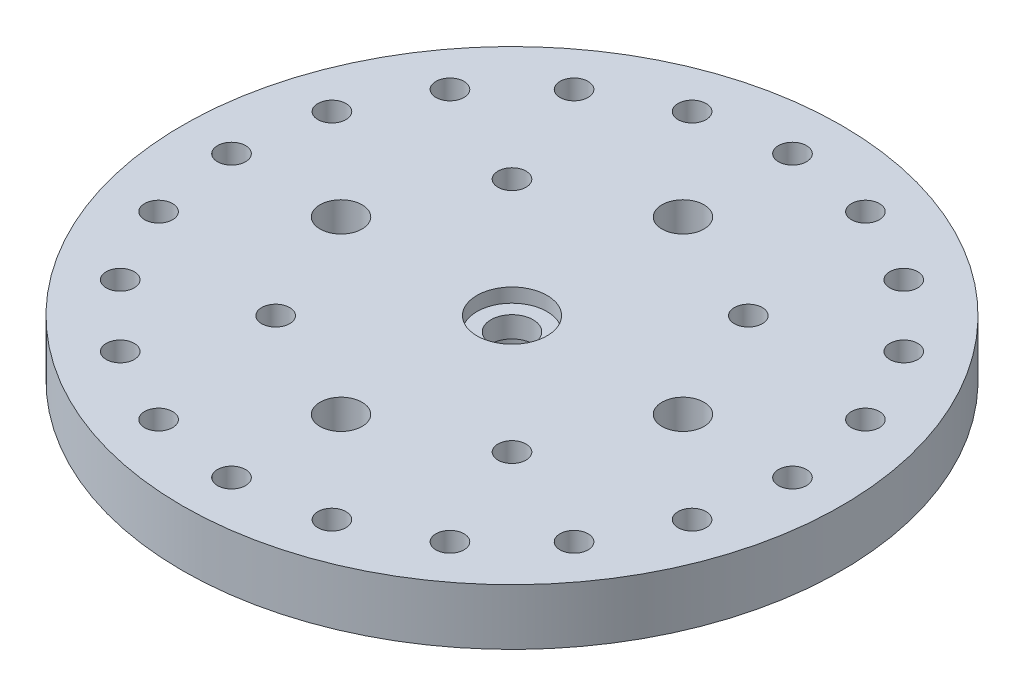
from build123d import *

# Parameters (mm, degrees)
SKETCH1_R           = 23.5
SKETCH1_R_2         = 1.5
SKETCH1_R_3         = 1
BOSS_EXTRUDE1_DEPTH = 4
SKETCH2_R           = 2.7
CUT_EXTRUDE1_DEPTH  = 1.5
SKETCH3_R           = 2.5
CUT_EXTRUDE2_DEPTH  = 1
SKETCH4_R           = 3.7
SKETCH4_R_2         = 2.7
EXTRUDE_THIN1_DEPTH = 1


with BuildPart() as part:
    # Sketch1 → Boss-Extrude1 (new body)
    with BuildSketch(Plane(origin=(0, 0, 0), x_dir=(1, 0, 0), z_dir=(0, 1, 0))):
        Circle(SKETCH1_R)
        Circle(SKETCH1_R_2, mode=Mode.SUBTRACT)
        with Locations((0, 20)):
            Circle(SKETCH1_R_3, mode=Mode.SUBTRACT)
        with Locations((6.180339887, 19.021130326)):
            Circle(SKETCH1_R_3, mode=Mode.SUBTRACT)
        with Locations((11.755705046, 16.180339887)):
            Circle(SKETCH1_R_3, mode=Mode.SUBTRACT)
        with Locations((16.180339887, 11.755705046)):
            Circle(SKETCH1_R_3, mode=Mode.SUBTRACT)
        with Locations((19.021130326, 6.180339887)):
            Circle(SKETCH1_R_3, mode=Mode.SUBTRACT)
        with Locations((20, 0)):
            Circle(SKETCH1_R_3, mode=Mode.SUBTRACT)
        with Locations((19.021130326, -6.180339887)):
            Circle(SKETCH1_R_3, mode=Mode.SUBTRACT)
        with Locations((16.180339887, -11.755705046)):
            Circle(SKETCH1_R_3, mode=Mode.SUBTRACT)
        with Locations((11.755705046, -16.180339887)):
            Circle(SKETCH1_R_3, mode=Mode.SUBTRACT)
        with Locations((6.180339887, -19.021130326)):
            Circle(SKETCH1_R_3, mode=Mode.SUBTRACT)
        with Locations((0, -20)):
            Circle(SKETCH1_R_3, mode=Mode.SUBTRACT)
        with Locations((-6.180339887, -19.021130326)):
            Circle(SKETCH1_R_3, mode=Mode.SUBTRACT)
        with Locations((-11.755705046, -16.180339887)):
            Circle(SKETCH1_R_3, mode=Mode.SUBTRACT)
        with Locations((-16.180339887, -11.755705046)):
            Circle(SKETCH1_R_3, mode=Mode.SUBTRACT)
        with Locations((-19.021130326, -6.180339887)):
            Circle(SKETCH1_R_3, mode=Mode.SUBTRACT)
        with Locations((-20, 0)):
            Circle(SKETCH1_R_3, mode=Mode.SUBTRACT)
        with Locations((-19.021130326, 6.180339887)):
            Circle(SKETCH1_R_3, mode=Mode.SUBTRACT)
        with Locations((-16.180339887, 11.755705046)):
            Circle(SKETCH1_R_3, mode=Mode.SUBTRACT)
        with Locations((-11.755705046, 16.180339887)):
            Circle(SKETCH1_R_3, mode=Mode.SUBTRACT)
        with Locations((-6.180339887, 19.021130326)):
            Circle(SKETCH1_R_3, mode=Mode.SUBTRACT)
        with Locations((0, 12.191930978)):
            Circle(SKETCH1_R_2, mode=Mode.SUBTRACT)
        with Locations((12.191930978, 0)):
            Circle(SKETCH1_R_2, mode=Mode.SUBTRACT)
        with Locations((0, -12.191930978)):
            Circle(SKETCH1_R_2, mode=Mode.SUBTRACT)
        with Locations((-12.191930978, 0)):
            Circle(SKETCH1_R_2, mode=Mode.SUBTRACT)
        with Locations((-8.4255338, 8.4255338)):
            Circle(SKETCH1_R_3, mode=Mode.SUBTRACT)
        with Locations((8.4255338, 8.4255338)):
            Circle(SKETCH1_R_3, mode=Mode.SUBTRACT)
        with Locations((8.4255338, -8.4255338)):
            Circle(SKETCH1_R_3, mode=Mode.SUBTRACT)
        with Locations((-8.4255338, -8.4255338)):
            Circle(SKETCH1_R_3, mode=Mode.SUBTRACT)
    extrude(amount=BOSS_EXTRUDE1_DEPTH)

    # Sketch2 → Cut-Extrude1 (cut)
    with BuildSketch(Plane.XZ):
        Circle(SKETCH2_R)
    extrude(amount=-CUT_EXTRUDE1_DEPTH, mode=Mode.SUBTRACT)

    # Sketch3 → Cut-Extrude2 (cut)
    with BuildSketch(Plane(origin=(0, 4, 0), x_dir=(1, 0, 0), z_dir=(0, 1, 0))):
        Circle(SKETCH3_R)
    extrude(amount=-CUT_EXTRUDE2_DEPTH, mode=Mode.SUBTRACT)

    # Sketch4 → Extrude-Thin1 (add)
    with BuildSketch(Plane.XZ):
        Circle(SKETCH4_R)
        Circle(SKETCH4_R_2, mode=Mode.SUBTRACT)
    extrude(amount=EXTRUDE_THIN1_DEPTH)


solid = part.part
